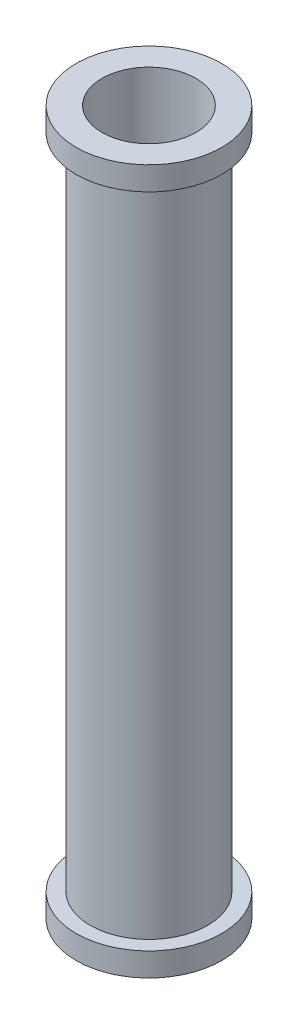
from build123d import *

# Parameters (mm, degrees)
SKETCH3_R   = 0.25
SKETCH3_R_2 = 0.2
SKETCH6_R   = 0.31
SKETCH6_R_2 = 0.21


with BuildPart() as part:
    # Sweep-Thin1: sweep along a path in Sketch1
    with BuildLine(Plane.XY) as sweep_thin1_path:
        Line((0, 0), (0, 1.5))
    # Sketch3 → Sweep-Thin1 (sweep)
    with BuildSketch(Plane(origin=(0, 0, 0), x_dir=(1, 0, 0), z_dir=(0, 1, 0))):
        Circle(SKETCH3_R)
        Circle(SKETCH3_R_2, mode=Mode.SUBTRACT)
    sweep(path=sweep_thin1_path.line)

    # Sweep-Thin2: sweep along a path in Sketch5
    with BuildLine(Plane.XY) as sweep_thin2_path:
        Line((0, 0), (0, 0.1))
    # Sketch6 → Sweep-Thin2 (sweep)
    with BuildSketch(Plane(origin=(0, 0, 0), x_dir=(1, 0, 0), z_dir=(0, 1, 0))):
        Circle(SKETCH6_R)
        Circle(SKETCH6_R_2, mode=Mode.SUBTRACT)
    sweep(path=sweep_thin2_path.line)

    # Mirror2: part across plane


with BuildPart() as part_1:
    add(part.part)
    add(part.part.mirror(Plane.ZX.offset(1.5)))


solid = part_1.part
